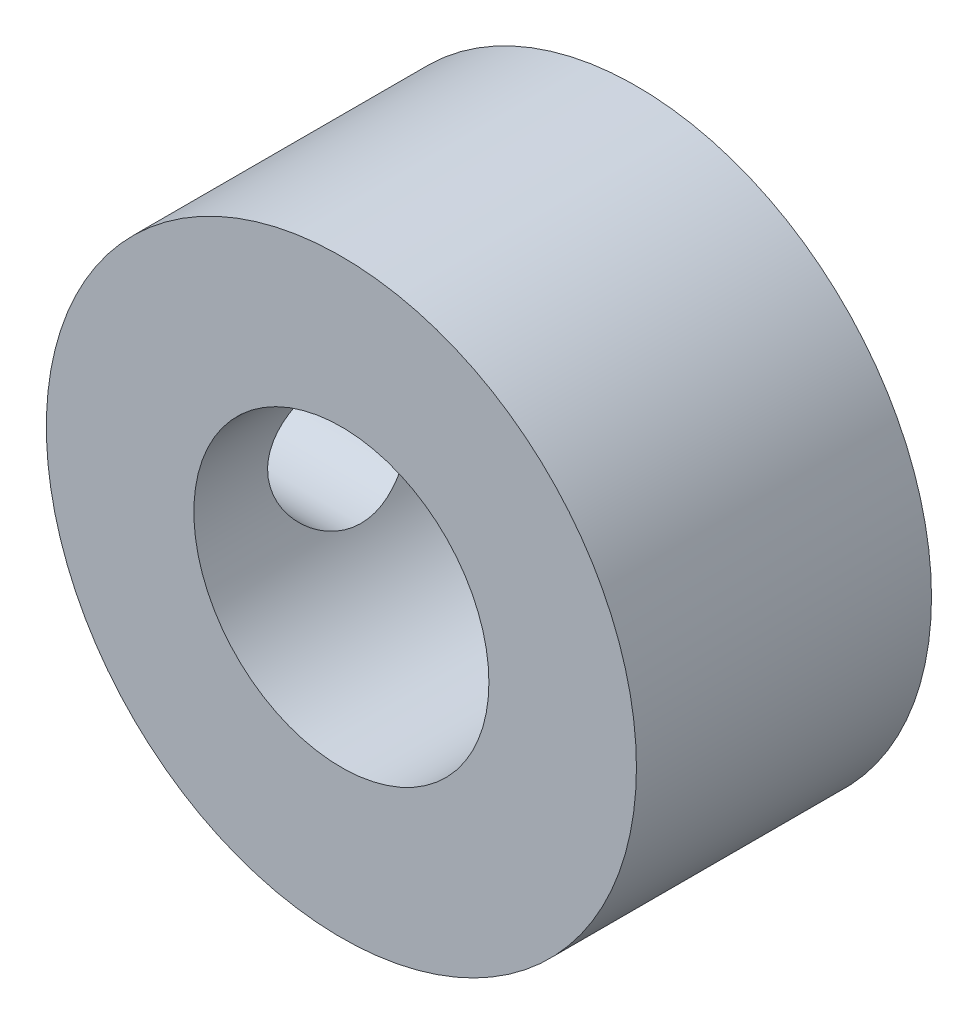
from build123d import *

# Parameters (mm, degrees)
SKETCH1_R           = 5
SKETCH1_R_2         = 2.5
BOSS_EXTRUDE1_DEPTH = 5
SKETCH2_R           = 1.25
CUT_EXTRUDE1_DEPTH  = 6


with BuildPart() as part:
    # Sketch1 → Boss-Extrude1 (new body)
    with BuildSketch(Plane.XY):
        Circle(SKETCH1_R)
        Circle(SKETCH1_R_2, mode=Mode.SUBTRACT)
    extrude(amount=BOSS_EXTRUDE1_DEPTH)

    # Sketch2 → Cut-Extrude1 (cut, through all)
    with BuildSketch(Plane(origin=(0, 0, 0), x_dir=(0, 0, -1), z_dir=(1, 0, 0))):
        with Locations((-2.5, 0)):
            Circle(SKETCH2_R)
    extrude(amount=-CUT_EXTRUDE1_DEPTH, mode=Mode.SUBTRACT)


solid = part.part
